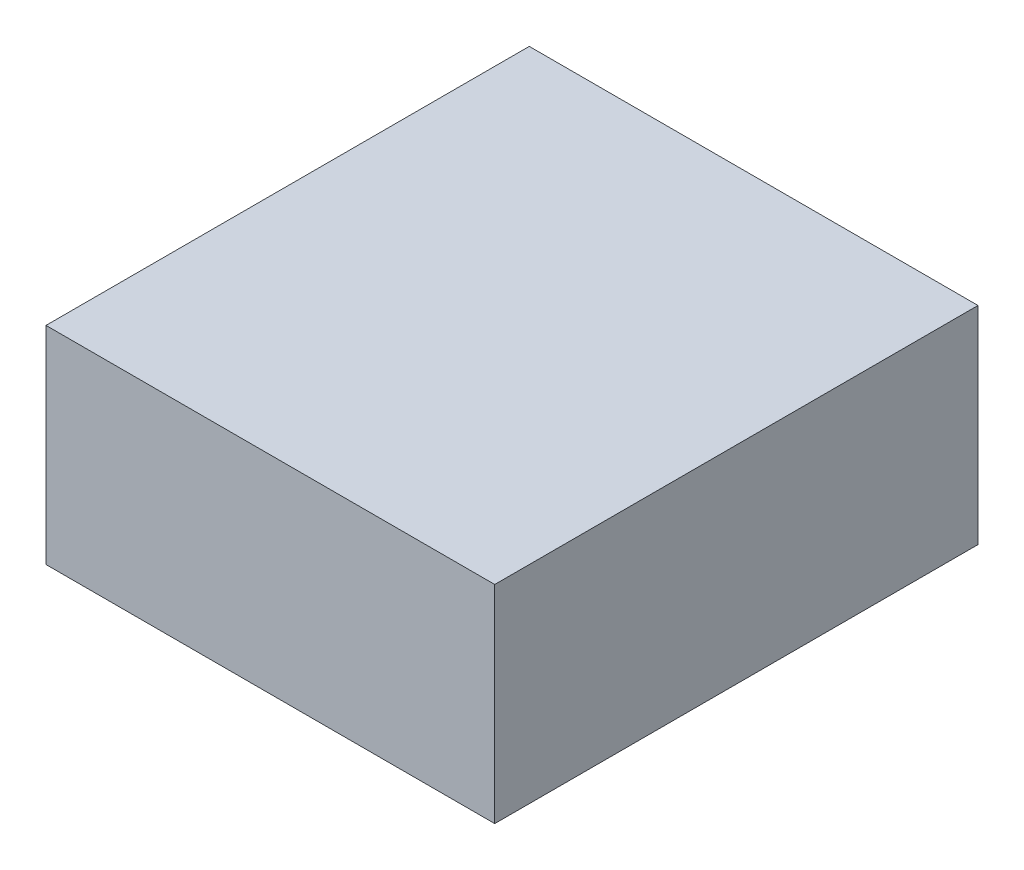
from build123d import *

# Parameters (mm, degrees)
SKETCH1_W           = 82.55
SKETCH1_H           = 88.9
BOSS_EXTRUDE1_DEPTH = 38.1


with BuildPart() as part:
    # Sketch1 → Boss-Extrude1 (new body)
    with BuildSketch(Plane(origin=(0, 0, 0), x_dir=(1, 0, 0), z_dir=(0, 1, 0))):
        with Locations((41.275, 44.45)):
            Rectangle(SKETCH1_W, SKETCH1_H)
    extrude(amount=BOSS_EXTRUDE1_DEPTH)


solid = part.part
